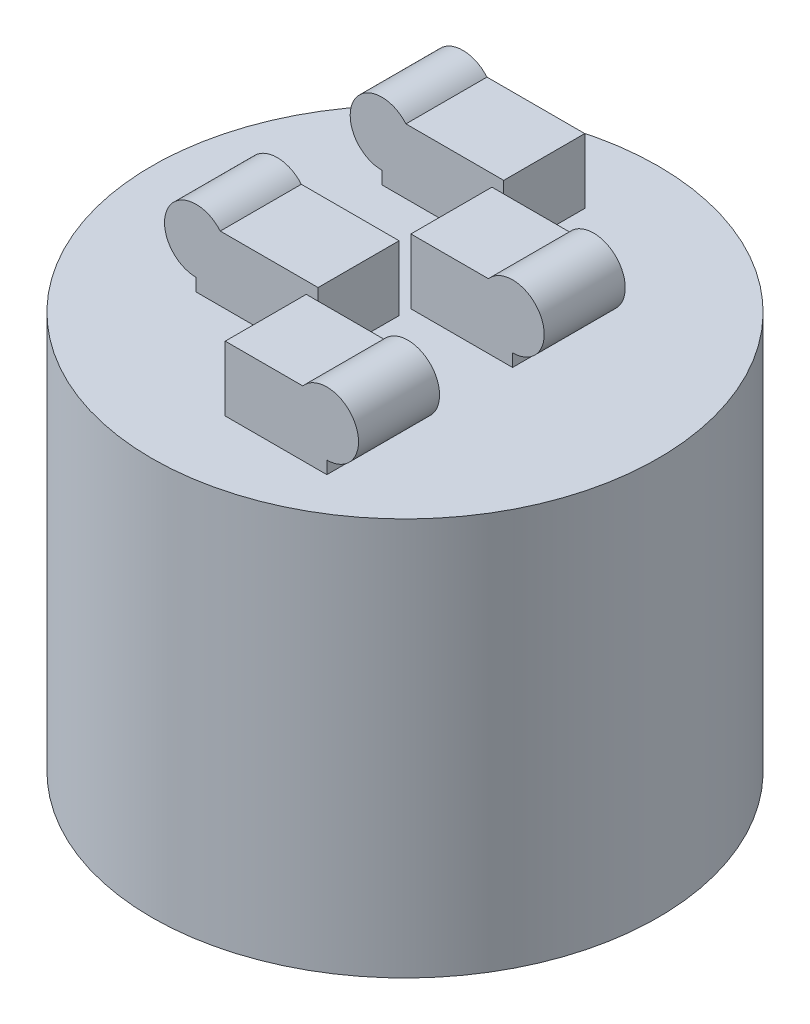
from build123d import *

# Parameters (mm, degrees)
SKETCH1_R           = 50
BOSS_EXTRUDE1_DEPTH = 78.5
BOSS_EXTRUDE2_DEPTH = 8
LPATTERN1_COUNT     = 2
LPATTERN1_PITCH     = 36.66
BOSS_EXTRUDE3_DEPTH = 8
LPATTERN2_COUNT     = 2
LPATTERN2_PITCH     = 36.66


with BuildPart() as part:
    # Sketch1 → Boss-Extrude1 (new body)
    with BuildSketch(Plane(origin=(0, 0, 0), x_dir=(1, 0, 0), z_dir=(0, 1, 0))):
        Circle(SKETCH1_R)
    extrude(amount=BOSS_EXTRUDE1_DEPTH)

    # Sketch2 → Boss-Extrude2 (add, symmetric)
    with BuildSketch(Plane.XY.offset(9.165)):
        with BuildLine():
            Line((0, 78.5), (-24.07, 78.5))
            Line((-24.07, 78.5), (-24.07, 81))
            ThreePointArc((-24.07, 81), (-29.743402859, 89.87202212), (-19.309747906, 91.3))
            Line((-19.309747906, 91.3), (0, 91.3))
            Line((0, 91.3), (0, 78.5))
        make_face()
    boss_extrude2 = extrude(amount=BOSS_EXTRUDE2_DEPTH, both=True)

    # LPattern1: Boss-Extrude2 ×2
    with Locations(*[(0, 0, -i * LPATTERN1_PITCH) for i in range(1, LPATTERN1_COUNT)]):
        add(boss_extrude2)

    # Sketch3 → Boss-Extrude3 (add, symmetric)
    with BuildSketch(Plane.XY.offset(27.495)):
        with BuildLine():
            Line((0, 91.3), (15.309747906, 91.3))
            ThreePointArc((15.309747906, 91.3), (25.743402859, 89.87202212), (20.07, 81))
            Line((20.07, 81), (20.07, 78.5))
            Line((20.07, 78.5), (0, 78.5))
            Line((0, 78.5), (0, 91.3))
        make_face()
    boss_extrude3 = extrude(amount=BOSS_EXTRUDE3_DEPTH, both=True)

    # LPattern2: Boss-Extrude3 ×2
    with Locations(*[(0, 0, -i * LPATTERN2_PITCH) for i in range(1, LPATTERN2_COUNT)]):
        add(boss_extrude3)


solid = part.part
